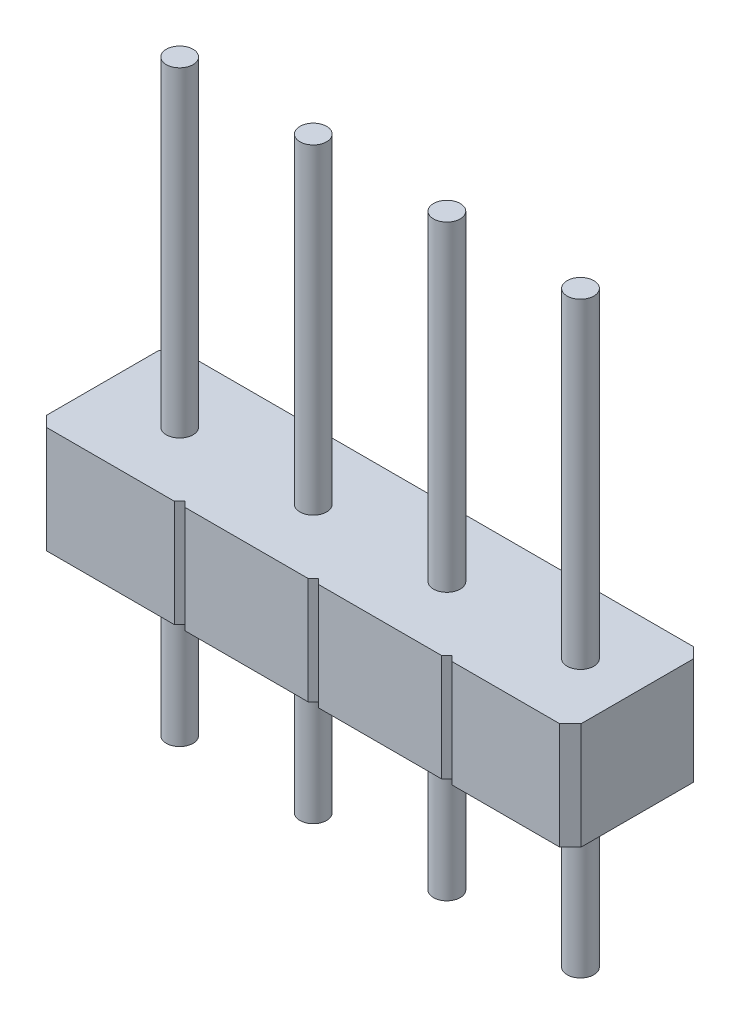
from build123d import *

# Parameters (mm, degrees)
IZIM1_R                          = 0.25
Y_KSEKLIK_EKSTR_ZYON1_DEPTH      = 2
IZIM2_R                          = 0.25
Y_KSEKLIK_EKSTR_ZYON2_DEPTH      = 6
Y_KSEKLIK_EKSTR_ZYON2_DEPTH_BACK = 5


with BuildPart() as part:
    # Çizim1 → Yükseklik-Ekstrüzyon1 (new body)
    with BuildSketch(Plane(origin=(0, 0, 0), x_dir=(1, 0, 0), z_dir=(0, 1, 0))):
        Polygon((-4.8, 1.25), (-2.412060191, 1.25), (-2.311389974, 1.122349253), (-2.210719757, 1.25), (0.088610026, 1.25), (0.188610026, 1.15), (0.288610026, 1.25), (2.588610026, 1.25), (2.688610026, 1.15), (2.788610026, 1.25), (4.8, 1.25), (5, 1.05), (5, -1.05), (4.8, -1.25), (2.788610026, -1.25), (2.688610026, -1.15), (2.588610026, -1.25), (0.288610026, -1.25), (0.188610026, -1.15), (0.088610026, -1.25), (-2.211389974, -1.25), (-2.311389974, -1.15), (-2.411389974, -1.25), (-4.8, -1.25), (-5, -1.05), (-5, 1.05), align=None)
        with Locations((-3.561389974, 0)):
            Circle(IZIM1_R, mode=Mode.SUBTRACT)
        with Locations((-1.061389974, 0)):
            Circle(IZIM1_R, mode=Mode.SUBTRACT)
        with Locations((1.438610026, 0)):
            Circle(IZIM1_R, mode=Mode.SUBTRACT)
        with Locations((3.938610026, 0)):
            Circle(IZIM1_R, mode=Mode.SUBTRACT)
    extrude(amount=Y_KSEKLIK_EKSTR_ZYON1_DEPTH)

    # Çizim2 → Yükseklik-Ekstrüzyon2 (add, two sides)
    with BuildSketch(Plane(origin=(0, 2, 0), x_dir=(1, 0, 0), z_dir=(0, 1, 0))) as y_kseklik_ekstr_zyon2_sk:
        with Locations((-3.561389974, 0)):
            Circle(IZIM2_R)
        with Locations((-1.061389974, 0)):
            Circle(IZIM2_R)
        with Locations((1.438610026, 0)):
            Circle(IZIM2_R)
        with Locations((3.938610026, 0)):
            Circle(IZIM2_R)
    extrude(amount=Y_KSEKLIK_EKSTR_ZYON2_DEPTH)
    extrude(y_kseklik_ekstr_zyon2_sk.sketch, amount=-Y_KSEKLIK_EKSTR_ZYON2_DEPTH_BACK)


solid = part.part
